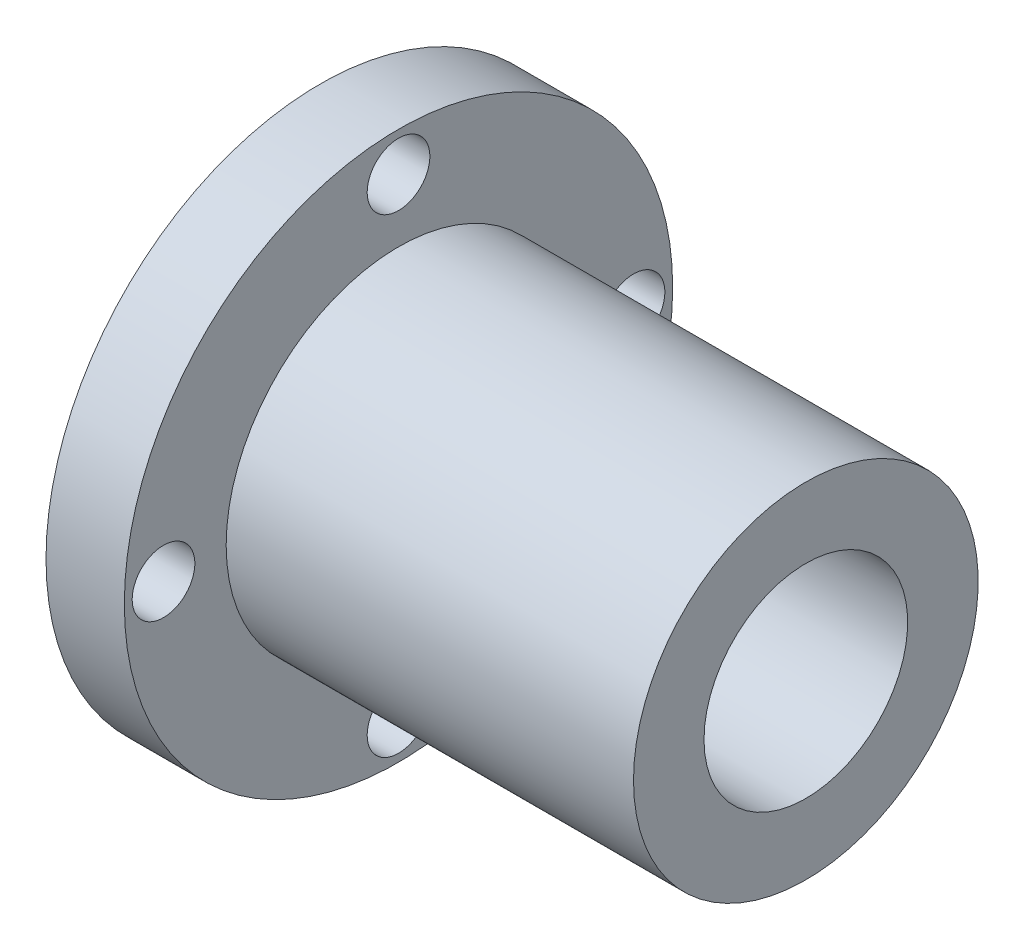
from build123d import *

# Parameters (mm, degrees)
ESQUISSE2_R      = 2
EXTRUSION1_DEPTH = 32


with BuildPart() as part:
    # Esquisse1 → Révolution1 (revolve)
    with BuildSketch(Plane.XY):
        Polygon((0, 10), (0, 17.5), (5, 17.5), (5, 11), (31, 11), (31, 6.5), (20, 6.5), (20, 10), align=None)
    revolve(axis=Axis((0, 0, 0), (1, 0, 0)))

    # Esquisse2 → Extrusion1 (cut, through all)
    with BuildSketch(Plane.ZY):
        with Locations((0, 15)):
            Circle(ESQUISSE2_R)
        with Locations((15, 0)):
            Circle(ESQUISSE2_R)
        with Locations((0, -15)):
            Circle(ESQUISSE2_R)
        with Locations((-15, 0)):
            Circle(ESQUISSE2_R)
    extrude(amount=-EXTRUSION1_DEPTH, mode=Mode.SUBTRACT)


solid = part.part
